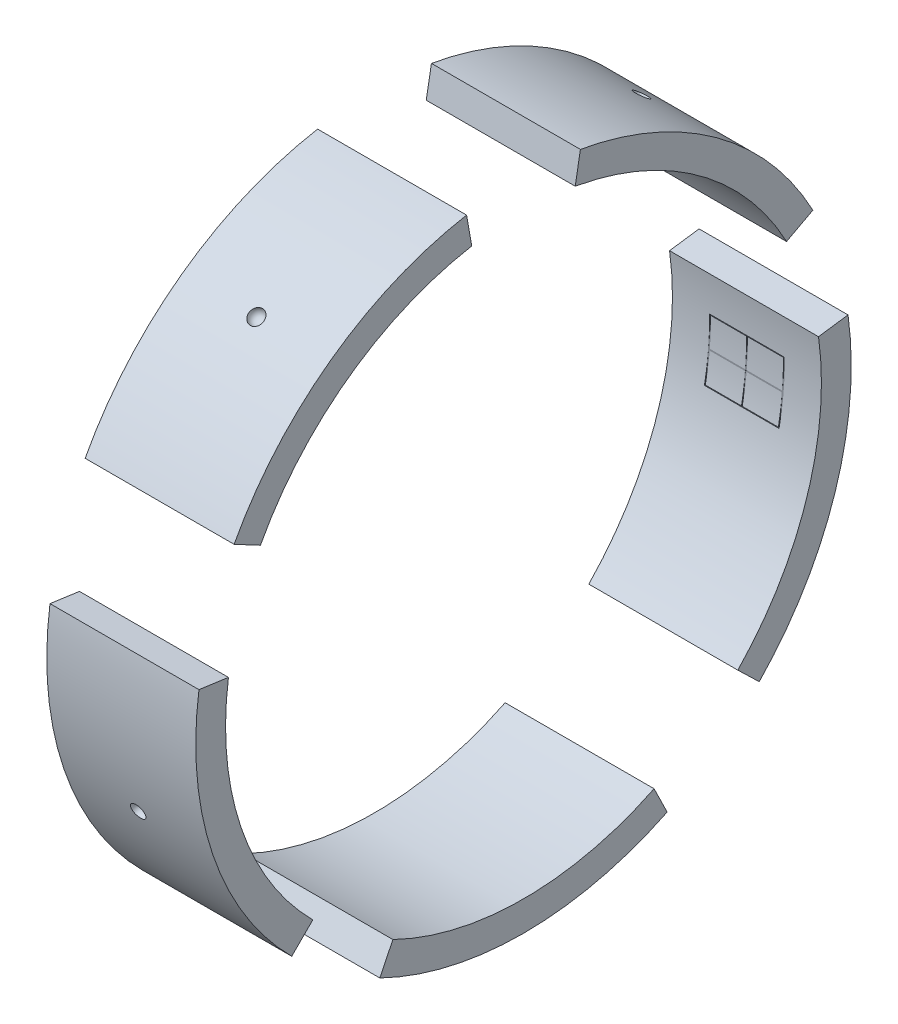
from build123d import *

# Parameters (mm, degrees)
BOSS_EXTRUDE1_DEPTH              = 100
BOSS_EXTRUDE1_2_DEPTH            = 100
BOSS_EXTRUDE1_3_DEPTH            = 100
BOSS_EXTRUDE1_4_DEPTH            = 100
BOSS_EXTRUDE1_5_DEPTH            = 100
F_1_2_13_TAPPED_HOLE1_AT_2_COUNT = 2
F_1_2_13_TAPPED_HOLE1_AT_2_PITCH = 94.479442824
F_1_2_13_TAPPED_HOLE1_AT_3_COUNT = 2
F_1_2_13_TAPPED_HOLE1_AT_3_PITCH = 164.107073965
F_1_2_13_TAPPED_HOLE1_AT_4_COUNT = 2
F_1_2_13_TAPPED_HOLE1_AT_4_PITCH = 246.869805963
F_1_2_13_TAPPED_HOLE1_AT_5_COUNT = 2
F_1_2_13_TAPPED_HOLE1_AT_5_PITCH = 361.224206733
F_1_2_13_TAPPED_HOLE1_AT_6_COUNT = 2
F_1_2_13_TAPPED_HOLE1_AT_6_PITCH = 400.096420653
F_1_2_13_TAPPED_HOLE1_AT_7_COUNT = 2
F_1_2_13_TAPPED_HOLE1_AT_7_PITCH = 418.401773199
F_1_2_13_TAPPED_HOLE1_AT_8_COUNT = 2
F_1_2_13_TAPPED_HOLE1_AT_8_PITCH = 246.869805963
F_1_2_13_TAPPED_HOLE1_AT_9_COUNT = 2
F_1_2_13_TAPPED_HOLE1_AT_9_PITCH = 316.978023694
SKETCH10_W                       = 50.099594842
SKETCH10_H                       = 39.875187732
SKETCH10_W_2                     = 49
SKETCH10_H_2                     = 39
CUT_EXTRUDE6_DEPTH               = 22
CUT_EXTRUDE7_DEPTH               = 28


with BuildPart() as part:
    # Sketch1 → Boss-Extrude1 (new body)
    with BuildSketch(Plane(origin=(0, 0, 0), x_dir=(0, 0, -1), z_dir=(1, 0, 0))):
        with BuildLine():
            Line((87.674229358, -179.75880926), (96.441652294, -197.734690186))
            ThreePointArc((96.441652294, -197.734690186), (0, -220), (-96.441652294, -197.734690186))
            Line((-96.441652294, -197.734690186), (-87.674229358, -179.75880926))
            ThreePointArc((-87.674229358, -179.75880926), (0, -200), (87.674229358, -179.75880926))
        make_face()
    extrude(amount=BOSS_EXTRUDE1_DEPTH)

    # Sketch6 → Cut-Revolve4 (revolve, cut)
    with BuildSketch(Plane(origin=(0, -220, 0), x_dir=(-1, 0, 0), z_dir=(0, -1, 0))):
        with BuildLine():
            Line((-55, 0), (-45, 0))
            ThreePointArc((-45, 0), (-50, -5), (-55, 0))
        make_face()
    revolve(axis=Axis((55, -220, 0), (-1, 0, 0)), mode=Mode.SUBTRACT)


with BuildPart() as body_2:
    # Sketch1 → Boss-Extrude1 2 (new body)
    with BuildSketch(Plane(origin=(0, 0, 0), x_dir=(0, 0, -1), z_dir=(1, 0, 0))):
        with BuildLine():
            Line((143.867960068, -138.931674092), (158.254756075, -152.824841501))
            ThreePointArc((158.254756075, -152.824841501), (209.232433585, -67.983738762), (217.858975123, 30.618082211))
            Line((217.858975123, 30.618082211), (198.053613748, 27.834620192))
            ThreePointArc((198.053613748, 27.834620192), (190.211303259, -61.803398875), (143.867960068, -138.931674092))
        make_face()
    extrude(amount=BOSS_EXTRUDE1_2_DEPTH)

    # Sketch5 → Cut-Revolve3 (revolve, cut)
    with BuildSketch(Plane(origin=(0, -67.983738762, -209.232433585), x_dir=(-1, 0, 0), z_dir=(0, -0.30901699437494823, -0.9510565162951534))):
        with BuildLine():
            Line((-55, 0), (-45, 0))
            ThreePointArc((-45, 0), (-50, 5), (-55, 0))
        make_face()
    revolve(axis=Axis((55, -67.983738762, -209.232433585), (-1, 0, 0)), mode=Mode.SUBTRACT)

    # Sketch9 → 1/2-13 Tapped Hole1 (revolve, cut)
    with BuildSketch(Plane(origin=(-10, -108.157995731, -180.005133147), x_dir=(0, 0, 1), z_dir=(0, 1, 0))):
        Polygon((0, 0), (0, 69.119489309), (5.35813, 65.9), (5.35813, 0), align=None)
    f_1_2_13_tapped_hole1 = revolve(axis=Axis((-16.35, -108.157995731, -180.005133147), (1, 0, 0)), mode=Mode.SUBTRACT)

    # 1/2-13 Tapped Hole1 at 2: 1/2-13 Tapped Hole1 ×2
    with Locations(*[Vector(0, 0.9510565162951556, -0.30901699437494123) * (i * F_1_2_13_TAPPED_HOLE1_AT_2_PITCH) for i in range(1, F_1_2_13_TAPPED_HOLE1_AT_2_COUNT)]):
        add(f_1_2_13_tapped_hole1, mode=Mode.SUBTRACT)

    # Sketch10 → Cut-Extrude6 (cut)
    with BuildSketch(Plane(origin=(-10, -17.43114855, -199.238939618), x_dir=(1, 0, 0), z_dir=(0, 0.08715574274765091, 0.9961946980917463))):
        with Locations((60, 0)):
            Rectangle(SKETCH10_W, SKETCH10_H)
        with Locations((60, 0)):
            Rectangle(SKETCH10_W_2, SKETCH10_H_2, mode=Mode.SUBTRACT)
    extrude(amount=CUT_EXTRUDE6_DEPTH, mode=Mode.SUBTRACT)

    # Sketch11 → Cut-Extrude7 (cut)
    with BuildSketch(Plane(origin=(-10, -17.43114855, -199.238939618), x_dir=(1, 0, 0), z_dir=(0, 0.08715574274765091, 0.9961946980917463))):
        Polygon((35.5, 0.25), (59.75, 0.25), (59.75, 19.5), (60.25, 19.5), (60.25, 0.25), (84.5, 0.25), (84.5, -0.25), (60.25, -0.25), (60.25, -19.5), (59.75, -19.5), (59.75, -0.25), (35.5, -0.25), align=None)
    extrude(amount=CUT_EXTRUDE7_DEPTH, mode=Mode.SUBTRACT)

    # Sketch16 → #78 (0.016) Diameter Hole2 (revolve, cut)
    with BuildSketch(Plane(origin=(50.000252368, -17.422829758, -199.239667418), x_dir=(0, -0.9961946980917463, 0.08715574274765078), z_dir=(1, 0, 0))):
        Polygon((0, 0), (0, 10.122094878), (0.2032, 10), (0.2032, 0), align=None)
    revolve(axis=Axis((50.000252368, -16.869390792, -192.913831085), (0, -0.08715574274765081, -0.9961946980917461)), mode=Mode.SUBTRACT)


with BuildPart() as body_3:
    # Sketch1 → Boss-Extrude1 3 (new body)
    with BuildSketch(Plane(origin=(0, 0, 0), x_dir=(0, 0, -1), z_dir=(1, 0, 0))):
        with BuildLine():
            Line((176.589518572, 93.894312557), (194.248470429, 103.283743813))
            ThreePointArc((194.248470429, 103.283743813), (129.312755504, 177.983738762), (38.202599087, 216.657705663))
            Line((38.202599087, 216.657705663), (34.729635533, 196.961550602))
            ThreePointArc((34.729635533, 196.961550602), (117.557050458, 161.803398875), (176.589518572, 93.894312557))
        make_face()
    extrude(amount=BOSS_EXTRUDE1_3_DEPTH)

    # Sketch4 → Cut-Revolve2 (revolve, cut)
    with BuildSketch(Plane(origin=(0, 177.983738762, -129.312755504), x_dir=(1, 0, 0), z_dir=(0, 0.8090169943749485, -0.5877852522924717))):
        with BuildLine():
            Line((45, 0), (55, 0))
            ThreePointArc((55, 0), (50, 5), (45, 0))
        make_face()
    revolve(axis=Axis((45, 177.983738762, -129.312755504), (1, 0, 0)), mode=Mode.SUBTRACT)

    # 1/2-13 Tapped Hole1 at 8: 1/2-13 Tapped Hole1 ×2
    with Locations(*[Vector(0, 0.9961946980917455, 0.08715574274765843) * (i * F_1_2_13_TAPPED_HOLE1_AT_8_PITCH) for i in range(1, F_1_2_13_TAPPED_HOLE1_AT_8_COUNT)]):
        add(f_1_2_13_tapped_hole1, mode=Mode.SUBTRACT)

    # 1/2-13 Tapped Hole1 at 9: 1/2-13 Tapped Hole1 ×2
    with Locations(*[Vector(0, 0.9510565162951534, 0.309016994374948) * (i * F_1_2_13_TAPPED_HOLE1_AT_9_PITCH) for i in range(1, F_1_2_13_TAPPED_HOLE1_AT_9_COUNT)]):
        add(f_1_2_13_tapped_hole1, mode=Mode.SUBTRACT)


with BuildPart() as body_4:
    # Sketch1 → Boss-Extrude1 4 (new body)
    with BuildSketch(Plane(origin=(0, 0, 0), x_dir=(0, 0, -1), z_dir=(1, 0, 0))):
        with BuildLine():
            Line((-34.729635533, 196.961550602), (-38.202599087, 216.657705663))
            ThreePointArc((-38.202599087, 216.657705663), (-129.312755504, 177.983738762), (-194.248470429, 103.283743813))
            Line((-194.248470429, 103.283743813), (-176.589518572, 93.894312557))
            ThreePointArc((-176.589518572, 93.894312557), (-117.557050458, 161.803398875), (-34.729635533, 196.961550602))
        make_face()
    extrude(amount=BOSS_EXTRUDE1_4_DEPTH)

    # Sketch2 → Cut-Revolve1 (revolve, cut)
    with BuildSketch(Plane(origin=(0, 177.983738762, 129.312755504), x_dir=(1, 0, 0), z_dir=(0, 0.8090169943749467, 0.5877852522924741))):
        with BuildLine():
            Line((45, 0), (55, 0))
            ThreePointArc((55, 0), (50, 5), (45, 0))
        make_face()
    revolve(axis=Axis((45, 177.983738762, 129.312755504), (1, 0, 0)), mode=Mode.SUBTRACT)

    # 1/2-13 Tapped Hole1 at 7: 1/2-13 Tapped Hole1 ×2
    with Locations(*[Vector(0, 0.5877852522924715, 0.8090169943749487) * (i * F_1_2_13_TAPPED_HOLE1_AT_7_PITCH) for i in range(1, F_1_2_13_TAPPED_HOLE1_AT_7_COUNT)]):
        add(f_1_2_13_tapped_hole1, mode=Mode.SUBTRACT)


with BuildPart() as body_5:
    # Sketch1 → Boss-Extrude1 5 (new body)
    with BuildSketch(Plane(origin=(0, 0, 0), x_dir=(0, 0, -1), z_dir=(1, 0, 0))):
        with BuildLine():
            Line((-198.053613748, 27.834620192), (-217.858975123, 30.618082211))
            ThreePointArc((-217.858975123, 30.618082211), (-208.631204145, -69.807024409), (-155.563491861, -155.563491861))
            Line((-155.563491861, -155.563491861), (-141.421356237, -141.421356237))
            ThreePointArc((-141.421356237, -141.421356237), (-189.664731041, -63.460931281), (-198.053613748, 27.834620192))
        make_face()
    extrude(amount=BOSS_EXTRUDE1_5_DEPTH)

    # Sketch7 → Cut-Revolve5 (revolve, cut)
    with BuildSketch(Plane(origin=(0, -69.807024409, 208.631204145), x_dir=(1, 0, 0), z_dir=(0, -0.31730465640509947, 0.9483236552061969))):
        with BuildLine():
            Line((45, 0), (55, 0))
            ThreePointArc((55, 0), (50, 5), (45, 0))
        make_face()
    revolve(axis=Axis((45, -69.807024409, 208.631204145), (1, 0, 0)), mode=Mode.SUBTRACT)

    # 1/2-13 Tapped Hole1 at 5: 1/2-13 Tapped Hole1 ×2
    with Locations(*[Vector(0, 0.007883864896511335, 0.9999689218542213) * (i * F_1_2_13_TAPPED_HOLE1_AT_5_PITCH) for i in range(1, F_1_2_13_TAPPED_HOLE1_AT_5_COUNT)]):
        add(f_1_2_13_tapped_hole1, mode=Mode.SUBTRACT)

    # 1/2-13 Tapped Hole1 at 6: 1/2-13 Tapped Hole1 ×2
    with Locations(*[Vector(0, 0.229898063444137, 0.9732147144513567) * (i * F_1_2_13_TAPPED_HOLE1_AT_6_PITCH) for i in range(1, F_1_2_13_TAPPED_HOLE1_AT_6_COUNT)]):
        add(f_1_2_13_tapped_hole1, mode=Mode.SUBTRACT)


with BuildPart() as part_1:
    add(part.part)

    # 1/2-13 Tapped Hole1 at 3: 1/2-13 Tapped Hole1 ×2
    with Locations(*[Vector(0, -0.5877852522924774, 0.8090169943749443) * (i * F_1_2_13_TAPPED_HOLE1_AT_3_PITCH) for i in range(1, F_1_2_13_TAPPED_HOLE1_AT_3_COUNT)]):
        add(f_1_2_13_tapped_hole1, mode=Mode.SUBTRACT)

    # 1/2-13 Tapped Hole1 at 4: 1/2-13 Tapped Hole1 ×2
    with Locations(*[Vector(0, -0.3907311284892781, 0.9205048534524386) * (i * F_1_2_13_TAPPED_HOLE1_AT_4_PITCH) for i in range(1, F_1_2_13_TAPPED_HOLE1_AT_4_COUNT)]):
        add(f_1_2_13_tapped_hole1, mode=Mode.SUBTRACT)


solid = Compound([body_2.part, body_3.part, body_4.part, body_5.part, part_1.part])
